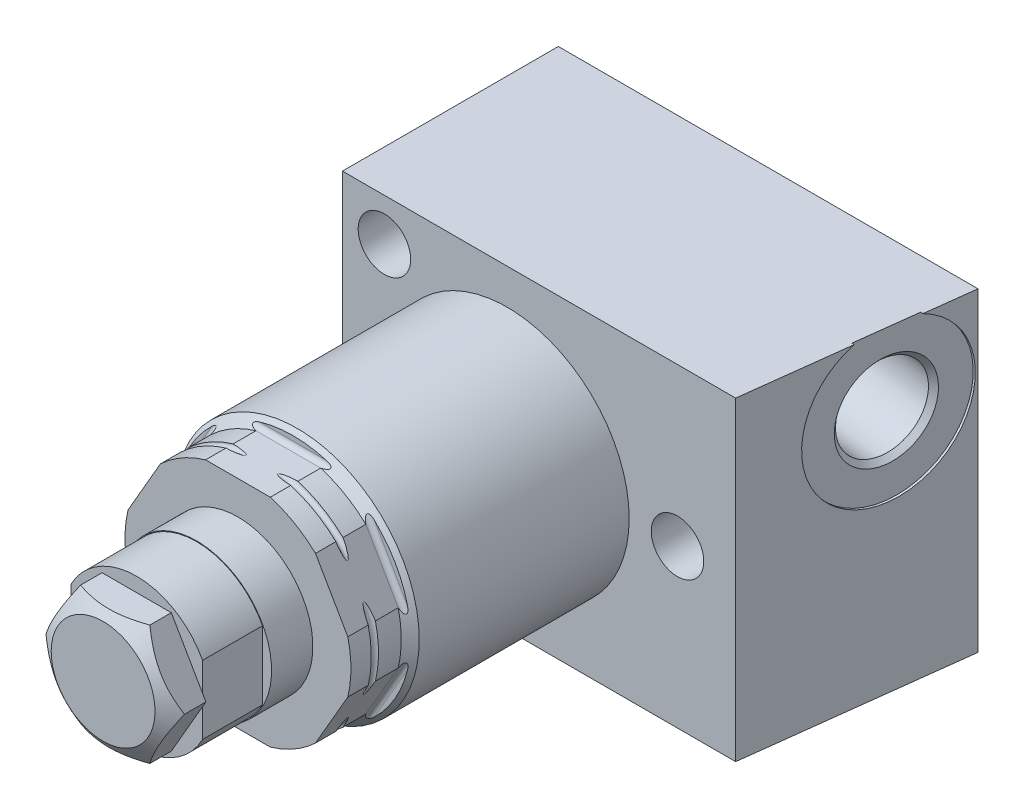
from build123d import *

# Parameters (mm, degrees)
CUT_EXTRUDE1_DEPTH      = 13.9159
CIRPATTERN1_COUNT       = 6
EXTRUDE1_DEPTH          = 16.6751
SKETCH3_W               = 10.724
SKETCH3_H               = 7.9375
SKETCH4_R               = 3.0226
CUT_EXTRUDE2_DEPTH      = 8.001
HOLE1_D                 = 5.5626
HOLE1_DEPTH             = 22.86
SKETCH10_W              = 0.9652
SKETCH10_H              = 6.35
CUT_EXTRUDE3_DEPTH      = 17.6751
CUT_EXTRUDE3_DEPTH_BACK = 17.6751
EXTRUDE2_DEPTH          = 3.556
SKETCH13_R              = 6.35
CUT_EXTRUDE4_DEPTH      = 2.54
HOLE2_D                 = 6.9088
HOLE2_DEPTH             = 12.192
HOLE2_TIP               = 2.075612922
SKETCH16_R              = 1.27
SKETCH17_W              = 6.35
SKETCH17_H              = 0.0775


with BuildPart() as part:
    # Sketch1 → Revolve1 (revolve)
    with BuildSketch(Plane(origin=(0, 0, 0), x_dir=(0, 0, -1), z_dir=(1, 0, 0)), mode=Mode.PRIVATE) as revolve1_sk:
        Polygon((0, 0), (0, 11.6713), (-7.112, 11.6713), (-8.3566, 12.9159), (-35.8267, 12.9159), (-36.7792, 11.9634), (-42.1132, 11.9634), (-42.1132, 0), align=None)
    revolve(revolve1_sk.sketch.rotate(Axis((0, 0, 0), (0, 0, -1)), 90), axis=Axis((0, 0, 0), (0, 0, -1)))  # turned: the seam where the file's is

    # Sketch2 → Cut-Extrude1 (cut, symmetric)
    with BuildSketch(Plane(origin=(0, 0, 0), x_dir=(0, 0, -1), z_dir=(1, 0, 0))):
        with BuildLine():
            Line((-42.1132, 11.46175), (-36.7792, 11.46175))
            ThreePointArc((-36.7792, 11.46175), (-36.419989755, 11.610539755), (-36.2712, 11.96975))
            Line((-36.2712, 11.96975), (-36.2712, 14.63675))
            Line((-36.2712, 14.63675), (-42.1132, 14.63675))
            Line((-42.1132, 14.63675), (-42.1132, 11.46175))
        make_face()
    cut_extrude1 = extrude(amount=CUT_EXTRUDE1_DEPTH, both=True, mode=Mode.SUBTRACT)

    # CirPattern1: Cut-Extrude1 ×6 about axis
    cirpattern1_axis = Axis((0, 0, 0), (0, 0, 1))
    for i in range(1, CIRPATTERN1_COUNT):
        add(cut_extrude1.rotate(cirpattern1_axis, i * 360 / CIRPATTERN1_COUNT), mode=Mode.SUBTRACT)

    # Sketch6 → Extrude1 (add, symmetric)
    with BuildSketch(Plane(origin=(0, 0, 0), x_dir=(1, 0, 0), z_dir=(0, 1, 0))):
        Polygon((-17.4498, -13.5932), (24.193344938, -13.5932), (27.0002, 9.2668), (-17.4498, 9.2668), align=None)
    extrude(amount=EXTRUDE1_DEPTH, both=True)

    # Sketch3 → Revolve2 (revolve)
    with BuildSketch(Plane(origin=(0, 0, 0), x_dir=(0, 0, -1), z_dir=(1, 0, 0)), mode=Mode.PRIVATE) as revolve2_sk:
        with Locations((-47.4752, 3.96875)):
            Rectangle(SKETCH3_W, SKETCH3_H)
    revolve(revolve2_sk.sketch.rotate(Axis((0, 0, 0), (0, 0, 1)), 103.349004362), axis=Axis((0, 0, 0), (0, 0, 1)))  # turned: the seam where the file's is

    # Sketch4 → Cut-Extrude2 (cut)
    with BuildSketch(Plane.XY.offset(52.8372)):
        Circle(SKETCH4_R)
    extrude(amount=-CUT_EXTRUDE2_DEPTH, mode=Mode.SUBTRACT)

    # Sketch5 → Cut-Revolve1 (revolve, cut)
    with BuildSketch(Plane(origin=(0, 0, 0), x_dir=(0, 0, -1), z_dir=(1, 0, 0)), mode=Mode.PRIVATE) as cut_revolve1_sk:
        with BuildLine():
            Line((-39.9542, 15.1384), (-39.9542, 11.9634))
            ThreePointArc((-39.9542, 11.9634), (-39.5732, 11.5824), (-39.1922, 11.9634))
            Line((-39.1922, 11.9634), (-39.1922, 15.1384))
            Line((-39.1922, 15.1384), (-39.9542, 15.1384))
        make_face()
    revolve(cut_revolve1_sk.sketch.rotate(Axis((0, 0, 0), (0, 0, 1)), 270), axis=Axis((0, 0, 0), (0, 0, 1)), mode=Mode.SUBTRACT)  # turned: the seam where the file's is

    # Hole1
    with Locations(Plane.XY.offset(13.5932)):
        with Locations((-13.0048, 12.192), (-13.0048, -12.192), (18.034, 0)):
            Hole(HOLE1_D / 2, depth=HOLE1_DEPTH)

    # Sketch9 → Cut-Revolve2 (revolve, cut)
    with BuildSketch(Plane(origin=(0, 9.0932, 0), x_dir=(-1, 0, 0), z_dir=(0, 1, 0)), mode=Mode.PRIVATE) as cut_revolve2_sk:
        Polygon((-24.957182327, 7.372243686), (-24.705075605, 7.341288873), (-25.107488177, 4.06390148), (-24.643069167, 3.469472255), (-14.684853628, 2.246757133), (-15.223467378, -2.139899839), (-25.963213757, -0.821224796), align=None)
    revolve(cut_revolve2_sk.sketch.rotate(Axis((25.963213757, 9.0932, -0.821224796), (-0.992546152, 0, -0.121869343)), 180), axis=Axis((25.963213757, 9.0932, -0.821224796), (-0.992546152, 0, -0.121869343)), mode=Mode.SUBTRACT)  # turned: the seam where the file's is

    # Sketch10 → Cut-Extrude3 (cut, two sides)
    with BuildSketch(Plane(origin=(0, 0, 0), x_dir=(1, 0, 0), z_dir=(0, 1, 0))) as cut_extrude3_sk:
        with Locations((7.4549, -49.6622)):
            Rectangle(SKETCH10_W, SKETCH10_H)
        with Locations((-7.4549, -49.6622)):
            Rectangle(SKETCH10_W, SKETCH10_H)
    extrude(amount=CUT_EXTRUDE3_DEPTH, mode=Mode.SUBTRACT)
    extrude(cut_extrude3_sk.sketch, amount=-CUT_EXTRUDE3_DEPTH_BACK, mode=Mode.SUBTRACT)

    # Sketch11 → Extrude2 (add)
    with BuildSketch(Plane.XY.offset(52.8372)):
        Polygon((3.666174209, 6.35), (-3.666174209, 6.35), (-7.332348419, 0), (-3.666174209, -6.35), (3.666174209, -6.35), (7.332348419, 0), align=None)
    extrude(amount=EXTRUDE2_DEPTH)

    # Sketch12 → Cut-Revolve3 (revolve, cut)
    with BuildSketch(Plane(origin=(0, 0, 0), x_dir=(1, 0, 0), z_dir=(0, 1, 0)), mode=Mode.PRIVATE) as cut_revolve3_sk:
        Polygon((-7.332348419, -55.109545638), (-7.332348419, -56.3932), (-5.4991, -56.3932), align=None)
    revolve(cut_revolve3_sk.sketch.rotate(Axis((0, 0, 0), (0, 0, 1)), 13.349004362), axis=Axis((0, 0, 0), (0, 0, 1)), mode=Mode.SUBTRACT)  # turned: the seam where the file's is

    # Sketch13 → Cut-Extrude4 (cut)
    with BuildSketch(Plane(origin=(0, 0, -9.2668), x_dir=(-1, 0, 0), z_dir=(0, 0, -1))):
        with Locations((-17.4752, -9.7155)):
            Circle(SKETCH13_R)
    extrude(amount=-CUT_EXTRUDE4_DEPTH, mode=Mode.SUBTRACT)

    # Hole2
    with Locations(Plane(origin=(0, 0, -6.7268), x_dir=(-1, 0, 0), z_dir=(0, 0, -1))):
        with Locations((-17.4752, -9.7155)):
            Hole(HOLE2_D / 2, depth=HOLE2_DEPTH)
            with Locations((0, 0, -(HOLE2_DEPTH + HOLE2_TIP / 2))):  # 118° drill point
                Cone(0, HOLE2_D / 2, HOLE2_TIP, mode=Mode.SUBTRACT)

    # Sketch17 → Cut-Revolve4 (revolve, cut)
    with BuildSketch(Plane(origin=(0, 0, 0), x_dir=(0, 0, -1), z_dir=(1, 0, 0)), mode=Mode.PRIVATE) as cut_revolve4_sk:
        with Locations((-49.6622, 7.89875)):
            Rectangle(SKETCH17_W, SKETCH17_H)
    revolve(cut_revolve4_sk.sketch.rotate(Axis((0, 0, -9.2668), (0, 0, 1)), 103.349004362), axis=Axis((0, 0, -9.2668), (0, 0, 1)), mode=Mode.SUBTRACT)  # turned: the seam where the file's is


with BuildPart() as body_2:
    # Sketch16 → Revolve3 (revolve)
    with BuildSketch(Plane.XZ.offset(9.7155), mode=Mode.PRIVATE) as revolve3_sk:
        with Locations((22.5552, -7.9968)):
            Circle(SKETCH16_R)
    revolve(revolve3_sk.sketch.rotate(Axis((17.4752, -9.7155, 7.540812922), (0, 0, -1)), 180), axis=Axis((17.4752, -9.7155, 7.540812922), (0, 0, -1)))  # turned: the seam where the file's is


solid = Compound([part.part, body_2.part])
